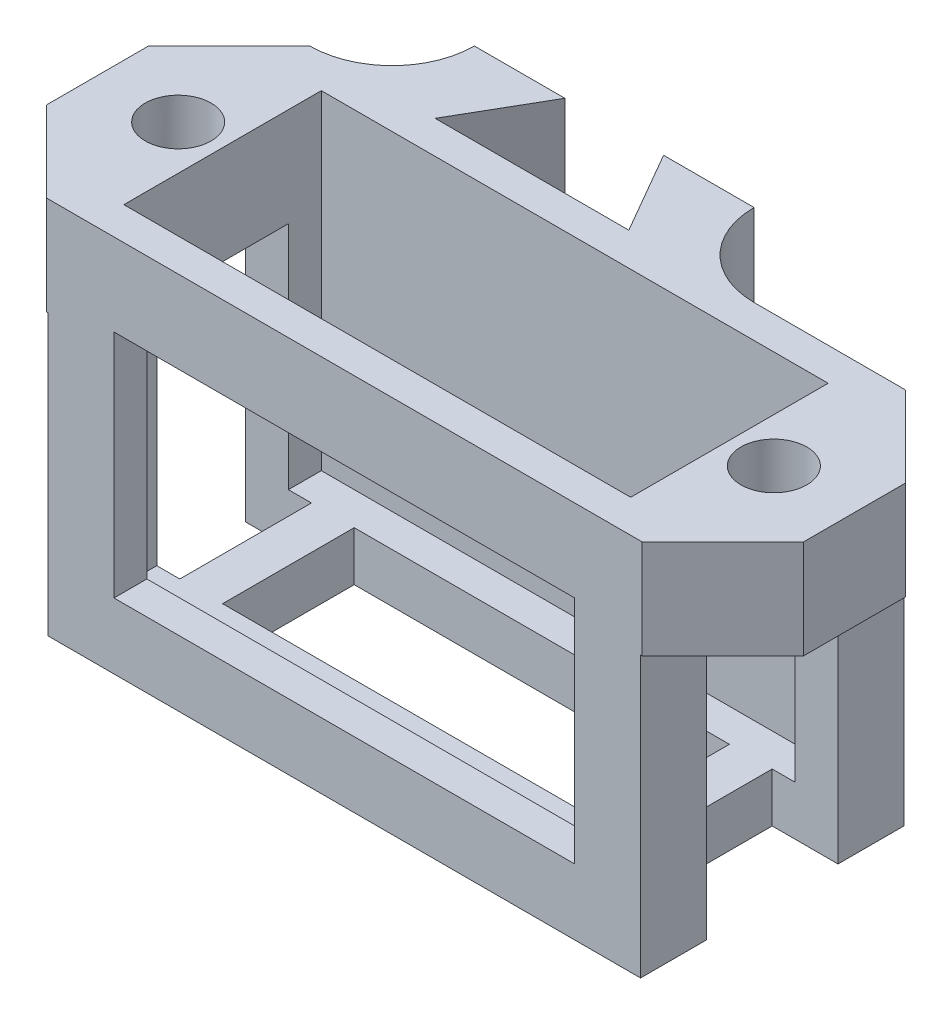
from build123d import *

# Parameters (mm, degrees)
SKETCH1_W      = 30
SKETCH1_H      = 15
SKETCH1_H_2    = 5
EXTRUDE1_DEPTH = 8
EXTRUDE2_START = 5
SKETCH2_R      = 2
SKETCH2_W      = 30.8
SKETCH2_H      = 12
SKETCH2_W_2    = 22.8
SKETCH2_H_2    = 8
EXTRUDE2_DEPTH = 20
EXTRUDE3_START = 8
SKETCH3_W      = 28
SKETCH3_H      = 14
EXTRUDE3_DEPTH = 14
EXTRUDE4_DEPTH = 4
EXTRUDE5_START = -15
SKETCH2_3_W    = 22.8
SKETCH2_3_H    = 8
EXTRUDE5_DEPTH = 3
EXTRUDE6_START = -18
EXTRUDE6_DEPTH = 23


with BuildPart() as part:
    # Sketch1 → Extrude1 (new, symmetric)
    with BuildSketch(Plane.XY):
        Polygon((-15, 0), (-15, 5), (-23, 5), (-23, -1), (-18, -1), (-18, -18), (18, -18), (18, -1), (23, -1), (23, 5), (15, 5), (15, 0), (15, -15), (-15, -15), align=None)
        with Locations((0, -7.5)):
            Rectangle(SKETCH1_W, SKETCH1_H)
        with Locations((0, 2.5)):
            Rectangle(SKETCH1_W, SKETCH1_H_2)
    extrude(amount=EXTRUDE1_DEPTH, both=True)

    # Sketch2 → Extrude2 (cut)
    with BuildSketch(Plane(origin=(0, 0, 0), x_dir=(1, 0, 0), z_dir=(0, 1, 0)).offset(EXTRUDE2_START)):
        Polygon((-23, -8), (-23, -3.1), (-18.1, -8), align=None)
        with Locations(Location((-18.1, 0, 0), (0, 0, 272.865983983))):
            Circle(SKETCH2_R)
        Polygon((-23, 8), (-18.1, 8), (-23, 3.1), align=None)
        Rectangle(SKETCH2_W, SKETCH2_H)
        Rectangle(SKETCH2_W_2, SKETCH2_H_2, mode=Mode.SUBTRACT)
        Rectangle(SKETCH2_W_2, SKETCH2_H_2)
        Polygon((23, 3.1), (23, 8), (18.1, 8), align=None)
        with Locations(Location((18.1, 0, 0), (0, 0, 267.134016017))):
            Circle(SKETCH2_R)
        Polygon((18.1, -8), (23, -8), (23, -3.1), align=None)
    extrude(amount=-EXTRUDE2_DEPTH, mode=Mode.SUBTRACT)

    # Sketch3 → Extrude3 (cut)
    with BuildSketch(Plane.XY.offset(EXTRUDE3_START)):
        with Locations((0, -7)):
            Rectangle(SKETCH3_W, SKETCH3_H)
    extrude(amount=-EXTRUDE3_DEPTH, mode=Mode.SUBTRACT)

    # Sketch3_3 → Extrude4 (cut, symmetric)
    with BuildSketch(Plane.XY):
        Polygon((-14, -18), (-14, -14), (-14, -1), (-18, -1), (-18, -18), align=None)
        Polygon((14, -1), (14, -14), (14, -18), (18, -18), (18, -1), align=None)
    extrude(amount=EXTRUDE4_DEPTH, both=True, mode=Mode.SUBTRACT)

    # Sketch2_3 → Extrude5 (cut)
    with BuildSketch(Plane(origin=(0, 0, 0), x_dir=(1, 0, 0), z_dir=(0, 1, 0)).offset(EXTRUDE5_START)):
        Rectangle(SKETCH2_3_W, SKETCH2_3_H)
    extrude(amount=-EXTRUDE5_DEPTH, mode=Mode.SUBTRACT)

    # Sketch4 → Extrude6 (add)
    with BuildSketch(Plane(origin=(0, 0, 0), x_dir=(1, 0, 0), z_dir=(0, 1, 0)).offset(EXTRUDE6_START)):
        with BuildLine():
            Line((-18.1, 8), (-13.1, 8))
            Line((-13.1, 8), (-13.1, 13))
            ThreePointArc((-13.1, 13), (-14.564466094, 9.464466094), (-18.1, 8))
        make_face()
        Polygon((-13.1, 13), (-13.1, 8), (-10.486751346, 8), (-7.6, 13), align=None)
        Polygon((1.286751346, 8), (3.9, 8), (3.9, 13), (-1.6, 13), align=None)
        with BuildLine():
            Line((3.9, 13), (3.9, 8))
            Line((3.9, 8), (8.9, 8))
            ThreePointArc((8.9, 8), (5.364466094, 9.464466094), (3.9, 13))
        make_face()
    extrude(amount=EXTRUDE6_DEPTH)


solid = part.part
